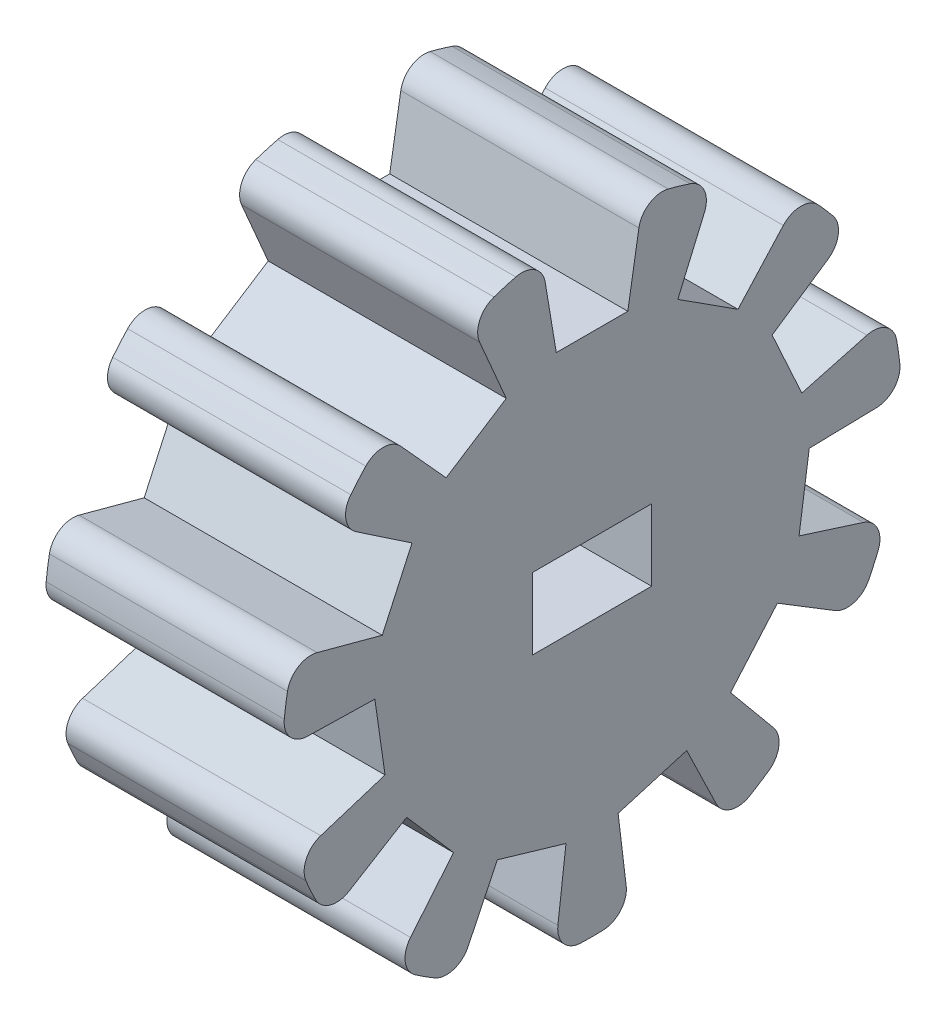
from build123d import *

# Parameters (mm, degrees)
SKETCH1_W                = 10
SKETCH1_H                = 13
CUT_EXTRUDE1_DEPTH       = 10
SKETCH7_W                = 5
SKETCH7_H                = 3
CUT_EXTRUDE2_DEPTH       = 10
FILLET1_R                = 1
CIRPATTERN1_COUNT        = 11
FILLET1_OF_CIRPATTERN1_R = 1


with BuildPart() as part:
    # Sketch1 → Revolve1 (revolve)
    with BuildSketch(Plane.XY):
        with Locations((-5, 6.5)):
            Rectangle(SKETCH1_W, SKETCH1_H)
    revolve(axis=Axis((-10, 0, 0), (-1, 0, 0)))

    # Sketch6 → Cut-Extrude1 (cut)
    with BuildSketch(Plane(origin=(0, 0, 0), x_dir=(0, 0, -1), z_dir=(1, 0, 0))):
        Polygon((-1.501758676, 9), (1.501758676, 9), (2.502016427, 15), (-2.502016427, 15), align=None)
    cut_extrude1 = extrude(amount=-CUT_EXTRUDE1_DEPTH, mode=Mode.SUBTRACT)

    # Sketch7 → Cut-Extrude2 (cut)
    with BuildSketch(Plane(origin=(0, 0, 0), x_dir=(0, 0, -1), z_dir=(1, 0, 0))):
        Rectangle(SKETCH7_W, SKETCH7_H)
    extrude(amount=-CUT_EXTRUDE2_DEPTH, mode=Mode.SUBTRACT)

    # Fillet1
    fillet1_edges = [part.edges().sort_by_distance(p)[0] for p in [
        (-5, 12.822809052, 2.13905774),
        (-5, 12.822809052, -2.13905774),
    ]]
    fillet(fillet1_edges, radius=FILLET1_R)

    # CirPattern1: Cut-Extrude1 ×11 about axis
    cirpattern1_axis = Axis((0, 0, 0), (1, 0, 0))
    for i in range(1, CIRPATTERN1_COUNT):
        add(cut_extrude1.rotate(cirpattern1_axis, i * 360 / CIRPATTERN1_COUNT), mode=Mode.SUBTRACT)

    # Fillet1 of CirPattern1
    fillet1_of_cirpattern1_edges = [part.edges().sort_by_distance(p)[0] for p in [
        (-5, 9.630771491, 8.732023849),
        (-5, 11.943695341, 5.133044087),
        (-5, 3.381032029, 12.552634083),
        (-5, 7.27254275, 10.775440685),
        (-5, -3.942161213, 12.387871688),
        (-5, 0.29240922, 12.996711001),
        (-5, -10.013746124, 8.290047561),
        (-5, -6.78056217, 11.091617405),
        (-5, -12.906037394, 1.560191908),
        (-5, -11.700752981, 5.665013652),
        (-5, -11.700752981, -5.665013652),
        (-5, -12.906037394, -1.560191908),
        (-5, -6.78056217, -11.091617405),
        (-5, -10.013746124, -8.290047561),
        (-5, 0.29240922, -12.996711001),
        (-5, -3.942161213, -12.387871688),
        (-5, 7.27254275, -10.775440685),
        (-5, 3.381032029, -12.552634083),
        (-5, 11.943695341, -5.133044087),
        (-5, 9.630771491, -8.732023849),
    ]]
    fillet(fillet1_of_cirpattern1_edges, radius=FILLET1_OF_CIRPATTERN1_R)


solid = part.part
